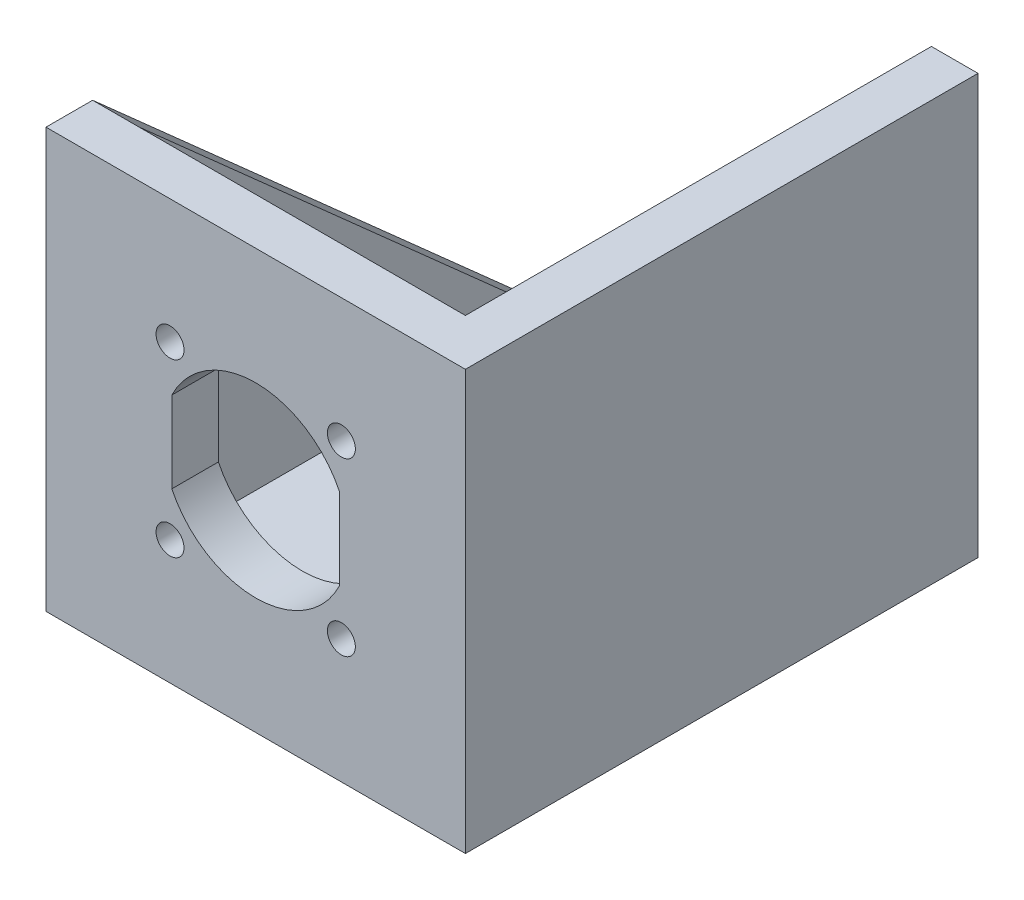
from build123d import *

# Parameters (mm, degrees)
ESQUISSE1_W             = 45
ESQUISSE1_H             = 45
ESQUISSE1_R             = 1.5
EXTRUSION1_DEPTH        = 5
ESQUISSE2_W             = 45
ESQUISSE2_H             = 5
EXTRUSION2_DEPTH        = 95
EXTRUSION3_DEPTH        = 5
ESQUISSE4_W             = 95
ESQUISSE4_H             = 40
EXTRUSION4_DEPTH        = 5
ESQUISSE5_W             = 100
ESQUISSE5_H             = 5
EXTRUSION5_DEPTH        = 40
ESQUISSE6_W             = 40
ESQUISSE6_H             = 40
EXTRUSION6_DEPTH        = 5
EXTRUSION7_DEPTH        = 5
ENL_V_MAT_EXTRU_1_REACH = 102
ESQUISSE8_R             = 1.5
ENL_V_MAT_EXTRU_2_REACH = 7
ESQUISSE9_R             = 1.5
ESQUISSE10_W            = 88.935907412
ESQUISSE10_H            = 49.014601793
ENL_V_MAT_EXTRU_3_DEPTH = 45
ESQUISSE11_W            = 62.142779394
ESQUISSE11_H            = 38.028527447
ENL_V_MAT_EXTRU_4_DEPTH = 40
ENL_V_MAT_EXTRU_5_REACH = 7
ESQUISSE12_R            = 2


with BuildPart() as part:
    # Esquisse1 → Extrusion1 (new body)
    with BuildSketch(Plane.XY):
        with Locations((22.5, 22.5)):
            Rectangle(ESQUISSE1_W, ESQUISSE1_H)
        with Locations((31.692388155, 31.692388155)):
            Circle(ESQUISSE1_R, mode=Mode.SUBTRACT)
        with Locations((31.692388155, 13.307611845)):
            Circle(ESQUISSE1_R, mode=Mode.SUBTRACT)
        with Locations((13.307611845, 13.307611845)):
            Circle(ESQUISSE1_R, mode=Mode.SUBTRACT)
        with Locations((13.307611845, 31.692388155)):
            Circle(ESQUISSE1_R, mode=Mode.SUBTRACT)
        with BuildLine():
            Line((13.5, 26.858898944), (13.5, 18.141101056))
            ThreePointArc((13.5, 18.141101056), (22.5, 12.5), (31.5, 18.141101056))
            Line((31.5, 18.141101056), (31.5, 26.858898944))
            ThreePointArc((31.5, 26.858898944), (22.5, 32.5), (13.5, 26.858898944))
        make_face(mode=Mode.SUBTRACT)
    extrude(amount=EXTRUSION1_DEPTH)

    # Esquisse2 → Extrusion2 (add)
    with BuildSketch(Plane.XY.offset(5)):
        with Locations((22.5, 2.5)):
            Rectangle(ESQUISSE2_W, ESQUISSE2_H)
    extrude(amount=EXTRUSION2_DEPTH)

    # Esquisse3 → Extrusion3 (add)
    with BuildSketch(Plane(origin=(45, 0, 0), x_dir=(0, 0, -1), z_dir=(1, 0, 0))):
        Polygon((-5, 5), (-5, 45), (-50, 5), align=None)
    extrude(amount=-EXTRUSION3_DEPTH)

    # Esquisse4 → Extrusion4 (add)
    with BuildSketch(Plane.ZY):
        with Locations((52.5, 25)):
            Rectangle(ESQUISSE4_W, ESQUISSE4_H)
    extrude(amount=-EXTRUSION4_DEPTH)

    # Esquisse5 → Extrusion5 (add)
    with BuildSketch(Plane.ZY):
        with Locations((50, 2.5)):
            Rectangle(ESQUISSE5_W, ESQUISSE5_H)
    extrude(amount=EXTRUSION5_DEPTH)

    # Esquisse6 → Extrusion6 (add)
    with BuildSketch(Plane.XY.offset(100)):
        with Locations((-20, 25)):
            Rectangle(ESQUISSE6_W, ESQUISSE6_H)
    extrude(amount=-EXTRUSION6_DEPTH)

    # Esquisse7 → Extrusion7 (add)
    with BuildSketch(Plane.ZY.offset(40)):
        Polygon((95, 5), (95, 45), (50, 5), align=None)
    extrude(amount=-EXTRUSION7_DEPTH)

    # Esquisse8 → Enlèv. mat.-Extru.1 (cut, up to next)
    with BuildSketch(Plane.XY.offset(100), mode=Mode.PRIVATE) as enl_v_mat_extru_1_sk1:
        with Locations((-26.692388155, 31.692388155)):
            Circle(ESQUISSE8_R)
    enl_v_mat_extru_1_tool1 = extrude(enl_v_mat_extru_1_sk1.sketch, amount=-ENL_V_MAT_EXTRU_1_REACH, mode=Mode.PRIVATE) & part.part
    add(enl_v_mat_extru_1_tool1.solids().sort_by_distance((-26.692388, 31.692388, 100))[0], mode=Mode.SUBTRACT)
    # Esquisse8 → Enlèv. mat.-Extru.1 (cut, up to next)
    with BuildSketch(Plane.XY.offset(100), mode=Mode.PRIVATE) as enl_v_mat_extru_1_sk2:
        with Locations((-26.692388155, 13.307611845)):
            Circle(ESQUISSE8_R)
    enl_v_mat_extru_1_tool2 = extrude(enl_v_mat_extru_1_sk2.sketch, amount=-ENL_V_MAT_EXTRU_1_REACH, mode=Mode.PRIVATE) & part.part
    add(enl_v_mat_extru_1_tool2.solids().sort_by_distance((-26.692388, 13.307612, 100))[0], mode=Mode.SUBTRACT)
    # Esquisse8 → Enlèv. mat.-Extru.1 (cut, up to next)
    with BuildSketch(Plane.XY.offset(100), mode=Mode.PRIVATE) as enl_v_mat_extru_1_sk3:
        with Locations((-8.307611845, 13.307611845)):
            Circle(ESQUISSE8_R)
    enl_v_mat_extru_1_tool3 = extrude(enl_v_mat_extru_1_sk3.sketch, amount=-ENL_V_MAT_EXTRU_1_REACH, mode=Mode.PRIVATE) & part.part
    add(enl_v_mat_extru_1_tool3.solids().sort_by_distance((-8.307612, 13.307612, 100))[0], mode=Mode.SUBTRACT)
    # Esquisse8 → Enlèv. mat.-Extru.1 (cut, up to next)
    with BuildSketch(Plane.XY.offset(100), mode=Mode.PRIVATE) as enl_v_mat_extru_1_sk4:
        with Locations((-8.307611845, 31.692388155)):
            Circle(ESQUISSE8_R)
    enl_v_mat_extru_1_tool4 = extrude(enl_v_mat_extru_1_sk4.sketch, amount=-ENL_V_MAT_EXTRU_1_REACH, mode=Mode.PRIVATE) & part.part
    add(enl_v_mat_extru_1_tool4.solids().sort_by_distance((-8.307612, 31.692388, 100))[0], mode=Mode.SUBTRACT)
    # Esquisse8 → Enlèv. mat.-Extru.1 (cut, up to next)
    with BuildSketch(Plane.XY.offset(100), mode=Mode.PRIVATE) as enl_v_mat_extru_1_sk5:
        with BuildLine():
            Line((-26.5, 18.141101056), (-26.5, 26.858898944))
            ThreePointArc((-26.5, 26.858898944), (-17.5, 32.5), (-8.5, 26.858898944))
            Line((-8.5, 26.858898944), (-8.5, 18.141101056))
            ThreePointArc((-8.5, 18.141101056), (-17.5, 12.5), (-26.5, 18.141101056))
        make_face()
    enl_v_mat_extru_1_tool5 = extrude(enl_v_mat_extru_1_sk5.sketch, amount=-ENL_V_MAT_EXTRU_1_REACH, mode=Mode.PRIVATE) & part.part
    add(enl_v_mat_extru_1_tool5.solids().sort_by_distance((-17.5, 22.5, 100))[0], mode=Mode.SUBTRACT)

    # Esquisse9 → Enlèv. mat.-Extru.2 (cut, up to next)
    with BuildSketch(Plane(origin=(0, 5, 0), x_dir=(-1, 0, 0), z_dir=(0, 1, 0)), mode=Mode.PRIVATE) as enl_v_mat_extru_2_sk1:
        with Locations((-40, 95)):
            Circle(ESQUISSE9_R)
    enl_v_mat_extru_2_tool1 = extrude(enl_v_mat_extru_2_sk1.sketch, amount=-ENL_V_MAT_EXTRU_2_REACH, mode=Mode.PRIVATE) & part.part
    add(enl_v_mat_extru_2_tool1.solids().sort_by_distance((40, 5, 95))[0], mode=Mode.SUBTRACT)
    # Esquisse9 → Enlèv. mat.-Extru.2 (cut, up to next)
    with BuildSketch(Plane(origin=(0, 5, 0), x_dir=(-1, 0, 0), z_dir=(0, 1, 0)), mode=Mode.PRIVATE) as enl_v_mat_extru_2_sk2:
        with Locations((-10, 95)):
            Circle(ESQUISSE9_R)
    enl_v_mat_extru_2_tool2 = extrude(enl_v_mat_extru_2_sk2.sketch, amount=-ENL_V_MAT_EXTRU_2_REACH, mode=Mode.PRIVATE) & part.part
    add(enl_v_mat_extru_2_tool2.solids().sort_by_distance((10, 5, 95))[0], mode=Mode.SUBTRACT)
    # Esquisse9 → Enlèv. mat.-Extru.2 (cut, up to next)
    with BuildSketch(Plane(origin=(0, 5, 0), x_dir=(-1, 0, 0), z_dir=(0, 1, 0)), mode=Mode.PRIVATE) as enl_v_mat_extru_2_sk3:
        with Locations((35, 5)):
            Circle(ESQUISSE9_R)
    enl_v_mat_extru_2_tool3 = extrude(enl_v_mat_extru_2_sk3.sketch, amount=-ENL_V_MAT_EXTRU_2_REACH, mode=Mode.PRIVATE) & part.part
    add(enl_v_mat_extru_2_tool3.solids().sort_by_distance((-35, 5, 5))[0], mode=Mode.SUBTRACT)
    # Esquisse9 → Enlèv. mat.-Extru.2 (cut, up to next)
    with BuildSketch(Plane(origin=(0, 5, 0), x_dir=(-1, 0, 0), z_dir=(0, 1, 0)), mode=Mode.PRIVATE) as enl_v_mat_extru_2_sk4:
        with Locations((5, 5)):
            Circle(ESQUISSE9_R)
    enl_v_mat_extru_2_tool4 = extrude(enl_v_mat_extru_2_sk4.sketch, amount=-ENL_V_MAT_EXTRU_2_REACH, mode=Mode.PRIVATE) & part.part
    add(enl_v_mat_extru_2_tool4.solids().sort_by_distance((-5, 5, 5))[0], mode=Mode.SUBTRACT)
    # Esquisse9 → Enlèv. mat.-Extru.2 (cut, up to next)
    with BuildSketch(Plane(origin=(0, 5, 0), x_dir=(-1, 0, 0), z_dir=(0, 1, 0)), mode=Mode.PRIVATE) as enl_v_mat_extru_2_sk5:
        with Locations((-40, 55)):
            Circle(ESQUISSE9_R)
    enl_v_mat_extru_2_tool5 = extrude(enl_v_mat_extru_2_sk5.sketch, amount=-ENL_V_MAT_EXTRU_2_REACH, mode=Mode.PRIVATE) & part.part
    add(enl_v_mat_extru_2_tool5.solids().sort_by_distance((40, 5, 55))[0], mode=Mode.SUBTRACT)
    # Esquisse9 → Enlèv. mat.-Extru.2 (cut, up to next)
    with BuildSketch(Plane(origin=(0, 5, 0), x_dir=(-1, 0, 0), z_dir=(0, 1, 0)), mode=Mode.PRIVATE) as enl_v_mat_extru_2_sk6:
        with Locations((35, 45)):
            Circle(ESQUISSE9_R)
    enl_v_mat_extru_2_tool6 = extrude(enl_v_mat_extru_2_sk6.sketch, amount=-ENL_V_MAT_EXTRU_2_REACH, mode=Mode.PRIVATE) & part.part
    add(enl_v_mat_extru_2_tool6.solids().sort_by_distance((-35, 5, 45))[0], mode=Mode.SUBTRACT)

    # Esquisse10 → Enlèv. mat.-Extru.3 (cut)
    with BuildSketch(Plane(origin=(0, 0, 0), x_dir=(-1, 0, 0), z_dir=(0, 0, -1))):
        with Locations((-0.532046294, 24.507300897)):
            Rectangle(ESQUISSE10_W, ESQUISSE10_H)
    extrude(amount=-ENL_V_MAT_EXTRU_3_DEPTH, mode=Mode.SUBTRACT)

    # Esquisse11 → Enlèv. mat.-Extru.4 (cut)
    with BuildSketch(Plane(origin=(45, 0, 0), x_dir=(0, 0, -1), z_dir=(1, 0, 0))):
        with Locations((-68.928610303, 19.014263724)):
            Rectangle(ESQUISSE11_W, ESQUISSE11_H)
    extrude(amount=-ENL_V_MAT_EXTRU_4_DEPTH, mode=Mode.SUBTRACT)

    # Esquisse12 → Enlèv. mat.-Extru.5 (cut, up to next)
    with BuildSketch(Plane(origin=(0, 5, 0), x_dir=(-1, 0, 0), z_dir=(0, 1, 0)), mode=Mode.PRIVATE) as enl_v_mat_extru_5_sk1:
        with Locations((19.890130801, 72.49689605)):
            Circle(ESQUISSE12_R)
    enl_v_mat_extru_5_tool1 = extrude(enl_v_mat_extru_5_sk1.sketch, amount=-ENL_V_MAT_EXTRU_5_REACH, mode=Mode.PRIVATE) & part.part
    add(enl_v_mat_extru_5_tool1.solids().sort_by_distance((-19.890131, 5, 72.496896))[0], mode=Mode.SUBTRACT)


solid = part.part
